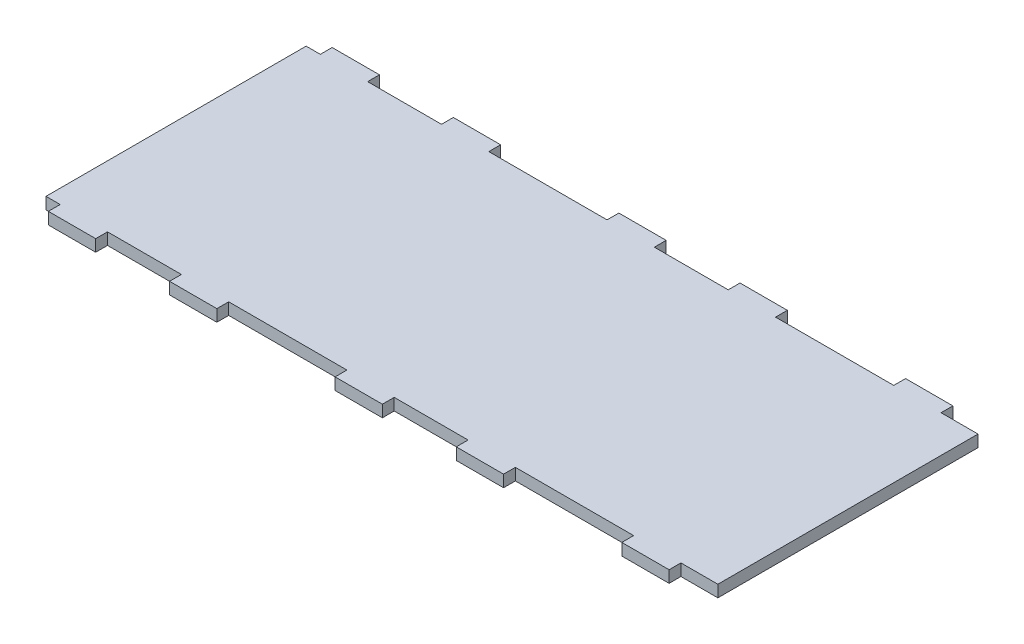
from build123d import *

# Parameters (mm, degrees)
SKETCH1_W                 = 721.63658441
SKETCH1_H                 = 152.4
BOSS_EXTRUDE1_DEPTH       = 6.35
SKETCH2_W                 = 39.679316882
SKETCH2_H                 = 6.35
SKETCH2_W_2               = 31.750000127
CUT_EXTRUDE1_DEPTH        = 7.35
LPATTERN1_COUNT           = 3
LPATTERN1_PITCH           = 153.979316882
LPATTERN1_COL_COUNT       = 3
LPATTERN1_COL_PITCH       = 153.979316882
MIRROR1_COPY_1_SKETCH_W   = 39.679316882
MIRROR1_COPY_1_SKETCH_H   = 6.35
MIRROR1_COPY_1_SKETCH_W_2 = 31.750000127
MIRROR1_COPY_1_DEPTH      = 7.35
MIRROR1_COPY_2_SKETCH_W   = 39.679316882
MIRROR1_COPY_2_SKETCH_H   = 6.35
MIRROR1_COPY_2_SKETCH_W_2 = 31.750000127
MIRROR1_COPY_2_DEPTH      = 7.35
MIRROR1_COPY_3_SKETCH_W   = 39.679316882
MIRROR1_COPY_3_SKETCH_H   = 6.35
MIRROR1_COPY_3_SKETCH_W_2 = 31.750000127
MIRROR1_COPY_3_DEPTH      = 7.35
MIRROR1_COPY_4_SKETCH_W   = 39.679316882
MIRROR1_COPY_4_SKETCH_H   = 6.35
MIRROR1_COPY_4_SKETCH_W_2 = 31.750000127
MIRROR1_COPY_4_DEPTH      = 7.35
SKETCH4_W                 = 360.818292205
SKETCH4_H                 = 152.4
CUT_EXTRUDE2_DEPTH        = 7.35


with BuildPart() as part:
    # Sketch1 → Boss-Extrude1 (new body)
    with BuildSketch(Plane(origin=(0, 0, 0), x_dir=(1, 0, 0), z_dir=(0, 1, 0))):
        Rectangle(SKETCH1_W, SKETCH1_H)
    extrude(amount=BOSS_EXTRUDE1_DEPTH)

    # Sketch2 → Cut-Extrude1 (cut, through all)
    with BuildSketch(Plane(origin=(0, 6.35, 0), x_dir=(1, 0, 0), z_dir=(0, 1, 0))):
        with Locations((0, -73.025)):
            Rectangle(SKETCH2_W, SKETCH2_H)
        with Locations((-61.114658505, -73.025)):
            Rectangle(SKETCH2_W_2, SKETCH2_H)
        with Locations((61.114658505, -73.025)):
            Rectangle(SKETCH2_W_2, SKETCH2_H)
    cut_extrude1 = extrude(amount=-CUT_EXTRUDE1_DEPTH, mode=Mode.SUBTRACT)

    # LPattern1: Cut-Extrude1 ×3
    with Locations(*[(i * LPATTERN1_PITCH, 0, 0) for i in range(1, LPATTERN1_COUNT)]):
        add(cut_extrude1, mode=Mode.SUBTRACT)

    # LPattern1 col: Cut-Extrude1 ×3
    with Locations(*[(-i * LPATTERN1_COL_PITCH, 0, 0) for i in range(1, LPATTERN1_COL_COUNT)]):
        add(cut_extrude1, mode=Mode.SUBTRACT)

    # Mirror1: Cut-Extrude1 across plane
    add(cut_extrude1.mirror(Plane.XY), mode=Mode.SUBTRACT)

    # Mirror1 copy 1 sketch → Mirror1 copy 1 (cut, through all)
    with BuildSketch(Plane(origin=(153.979316882, 6.35, 0), x_dir=(1, 0, 0), z_dir=(0, 1, 0))):
        with Locations((0, 73.025)):
            Rectangle(MIRROR1_COPY_1_SKETCH_W, MIRROR1_COPY_1_SKETCH_H)
        with Locations((-61.114658505, 73.025)):
            Rectangle(MIRROR1_COPY_1_SKETCH_W_2, MIRROR1_COPY_1_SKETCH_H)
        with Locations((61.114658505, 73.025)):
            Rectangle(MIRROR1_COPY_1_SKETCH_W_2, MIRROR1_COPY_1_SKETCH_H)
    extrude(amount=-MIRROR1_COPY_1_DEPTH, mode=Mode.SUBTRACT)

    # Mirror1 copy 2 sketch → Mirror1 copy 2 (cut, through all)
    with BuildSketch(Plane(origin=(307.958633764, 6.35, 0), x_dir=(1, 0, 0), z_dir=(0, 1, 0))):
        with Locations((0, 73.025)):
            Rectangle(MIRROR1_COPY_2_SKETCH_W, MIRROR1_COPY_2_SKETCH_H)
        with Locations((-61.114658505, 73.025)):
            Rectangle(MIRROR1_COPY_2_SKETCH_W_2, MIRROR1_COPY_2_SKETCH_H)
        with Locations((61.114658505, 73.025)):
            Rectangle(MIRROR1_COPY_2_SKETCH_W_2, MIRROR1_COPY_2_SKETCH_H)
    extrude(amount=-MIRROR1_COPY_2_DEPTH, mode=Mode.SUBTRACT)

    # Mirror1 copy 3 sketch → Mirror1 copy 3 (cut, through all)
    with BuildSketch(Plane(origin=(-153.979316882, 6.35, 0), x_dir=(1, 0, 0), z_dir=(0, 1, 0))):
        with Locations((0, 73.025)):
            Rectangle(MIRROR1_COPY_3_SKETCH_W, MIRROR1_COPY_3_SKETCH_H)
        with Locations((-61.114658505, 73.025)):
            Rectangle(MIRROR1_COPY_3_SKETCH_W_2, MIRROR1_COPY_3_SKETCH_H)
        with Locations((61.114658505, 73.025)):
            Rectangle(MIRROR1_COPY_3_SKETCH_W_2, MIRROR1_COPY_3_SKETCH_H)
    extrude(amount=-MIRROR1_COPY_3_DEPTH, mode=Mode.SUBTRACT)

    # Mirror1 copy 4 sketch → Mirror1 copy 4 (cut, through all)
    with BuildSketch(Plane(origin=(-307.958633764, 6.35, 0), x_dir=(1, 0, 0), z_dir=(0, 1, 0))):
        with Locations((0, 73.025)):
            Rectangle(MIRROR1_COPY_4_SKETCH_W, MIRROR1_COPY_4_SKETCH_H)
        with Locations((-61.114658505, 73.025)):
            Rectangle(MIRROR1_COPY_4_SKETCH_W_2, MIRROR1_COPY_4_SKETCH_H)
        with Locations((61.114658505, 73.025)):
            Rectangle(MIRROR1_COPY_4_SKETCH_W_2, MIRROR1_COPY_4_SKETCH_H)
    extrude(amount=-MIRROR1_COPY_4_DEPTH, mode=Mode.SUBTRACT)

    # Sketch4 → Cut-Extrude2 (cut, through all)
    with BuildSketch(Plane(origin=(0, 6.35, 0), x_dir=(1, 0, 0), z_dir=(0, 1, 0))):
        with Locations((180.409146103, 0)):
            Rectangle(SKETCH4_W, SKETCH4_H)
    extrude(amount=-CUT_EXTRUDE2_DEPTH, mode=Mode.SUBTRACT)


solid = part.part
